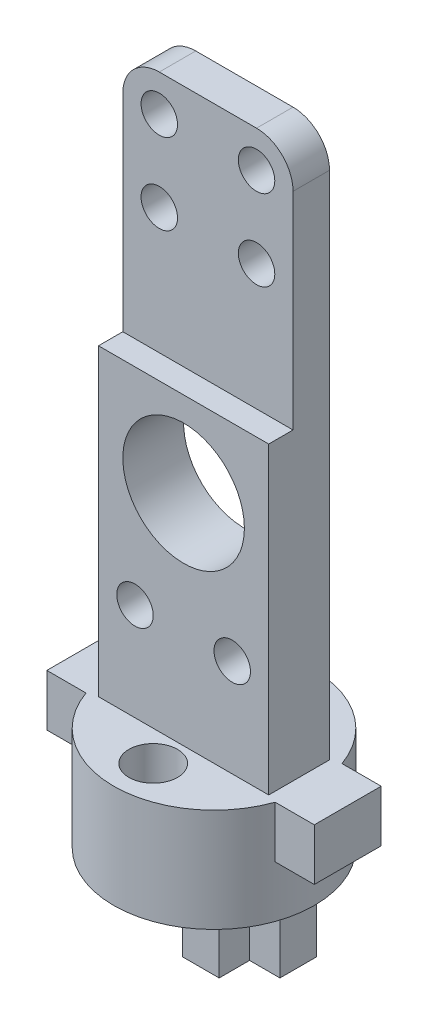
from build123d import *

# Parameters (mm, degrees)
BOSS_EXTRU_1_DEPTH      = 4.25
BOSS_EXTRU_2_DEPTH      = 4.25
ESQUISSE2_R             = 2
ENL_V_MAT_EXTRU_1_DEPTH = 8.5
ESQUISSE3_W             = 2.5
ESQUISSE3_H             = 3
ESQUISSE3_W_2           = 3
ESQUISSE3_H_2           = 2.5
BOSS_EXTRU_3_DEPTH      = 8
ESQUISSE4_W             = 14
ESQUISSE4_H             = 5
BOSS_EXTRU_4_DEPTH      = 45
ESQUISSE5_R             = 1.5
ESQUISSE5_R_2           = 5
ENL_V_MAT_EXTRU_2_DEPTH = 5
CONG_1_R                = 3
ESQUISSE6_W             = 2
ESQUISSE6_H             = 20
ENL_V_MAT_EXTRU_4_DEPTH = 14


with BuildPart() as part:
    # Esquisse1 → Boss.-Extru.1 (new body, symmetric)
    with BuildSketch(Plane(origin=(0, 0, 0), x_dir=(1, 0, 0), z_dir=(0, 1, 0))):
        with BuildLine():
            Line((7.778174593, -2.75), (-7.778174593, -2.75))
            ThreePointArc((-7.778174593, -2.75), (0, -8.25), (7.778174593, -2.75))
        make_face()
        with BuildLine():
            Line((7.778174593, 2.75), (-7.778174593, 2.75))
            ThreePointArc((-7.778174593, 2.75), (-8.25, 0), (-7.778174593, -2.75))
            Line((-7.778174593, -2.75), (7.778174593, -2.75))
            ThreePointArc((7.778174593, -2.75), (8.131188117, -1.395091324), (8.25, 0))
            ThreePointArc((8.25, 0), (8.131188117, 1.395091324), (7.778174593, 2.75))
        make_face()
        with BuildLine():
            ThreePointArc((7.778174593, 2.75), (0, 8.25), (-7.778174593, 2.75))
            Line((-7.778174593, 2.75), (7.778174593, 2.75))
        make_face()
    extrude(amount=BOSS_EXTRU_1_DEPTH, both=True)

    # Esquisse1_3 → Boss.-Extru.2 (add)
    with BuildSketch(Plane(origin=(0, 0, 0), x_dir=(1, 0, 0), z_dir=(0, 1, 0))):
        with BuildLine():
            Line((-7.778174593, 2.75), (-11, 2.75))
            Line((-11, 2.75), (-11, -2.75))
            Line((-11, -2.75), (-7.778174593, -2.75))
            ThreePointArc((-7.778174593, -2.75), (-8.25, 0), (-7.778174593, 2.75))
        make_face()
        with BuildLine():
            Line((11, 2.75), (7.778174593, 2.75))
            ThreePointArc((7.778174593, 2.75), (8.131188117, 1.395091324), (8.25, 0))
            ThreePointArc((8.25, 0), (8.131188117, -1.395091324), (7.778174593, -2.75))
            Line((7.778174593, -2.75), (11, -2.75))
            Line((11, -2.75), (11, 2.75))
        make_face()
    extrude(amount=BOSS_EXTRU_2_DEPTH)

    # Esquisse2 → Enlèv. mat.-Extru.1 (cut)
    with BuildSketch(Plane(origin=(0, 4.25, 0), x_dir=(1, 0, 0), z_dir=(0, 1, 0))):
        with Locations((0, -5)):
            Circle(ESQUISSE2_R)
    extrude(amount=-ENL_V_MAT_EXTRU_1_DEPTH, mode=Mode.SUBTRACT)

    # Esquisse3 → Boss.-Extru.3 (add)
    with BuildSketch(Plane.XZ.offset(4.25)):
        with Locations((-2.75, -2.924762745)):
            Rectangle(ESQUISSE3_W, ESQUISSE3_H)
        with Locations((0, -0.174762745)):
            Rectangle(ESQUISSE3_W_2, ESQUISSE3_H_2)
        with Locations((0, -2.924762745)):
            Rectangle(ESQUISSE3_W_2, ESQUISSE3_H)
        with Locations((0, -5.674762745)):
            Rectangle(ESQUISSE3_W_2, ESQUISSE3_H_2)
        with Locations((2.75, -2.924762745)):
            Rectangle(ESQUISSE3_W, ESQUISSE3_H)
    extrude(amount=BOSS_EXTRU_3_DEPTH)

    # Esquisse4 → Boss.-Extru.4 (add)
    with BuildSketch(Plane(origin=(0, 4.25, 0), x_dir=(1, 0, 0), z_dir=(0, 1, 0))):
        Rectangle(ESQUISSE4_W, ESQUISSE4_H)
    extrude(amount=BOSS_EXTRU_4_DEPTH)

    # Esquisse5 → Enlèv. mat.-Extru.2 (cut)
    with BuildSketch(Plane.XY.offset(2.5)):
        with Locations((-4, 46.25)):
            Circle(ESQUISSE5_R)
        with Locations((4, 46.25)):
            Circle(ESQUISSE5_R)
        with Locations((-4, 39.60357113)):
            Circle(ESQUISSE5_R)
        with Locations((4, 39.60357113)):
            Circle(ESQUISSE5_R)
        with Locations((0, 22.25)):
            Circle(ESQUISSE5_R_2)
        with Locations((-4, 12.278847644)):
            Circle(ESQUISSE5_R)
        with Locations((4, 12.278847644)):
            Circle(ESQUISSE5_R)
    extrude(amount=-ENL_V_MAT_EXTRU_2_DEPTH, mode=Mode.SUBTRACT)

    # Congé1
    cong_1_edges = [part.edges().sort_by_distance(p)[0] for p in [
        (-7, 49.25, 0),
        (7, 49.25, 0),
    ]]
    fillet(cong_1_edges, radius=CONG_1_R)

    # Esquisse6 → Enlèv. mat.-Extru.4 (cut)
    with BuildSketch(Plane(origin=(7, 0, 0), x_dir=(0, 0, -1), z_dir=(1, 0, 0))):
        with Locations((-1.5, 39.25)):
            Rectangle(ESQUISSE6_W, ESQUISSE6_H)
    extrude(amount=-ENL_V_MAT_EXTRU_4_DEPTH, mode=Mode.SUBTRACT)


solid = part.part
